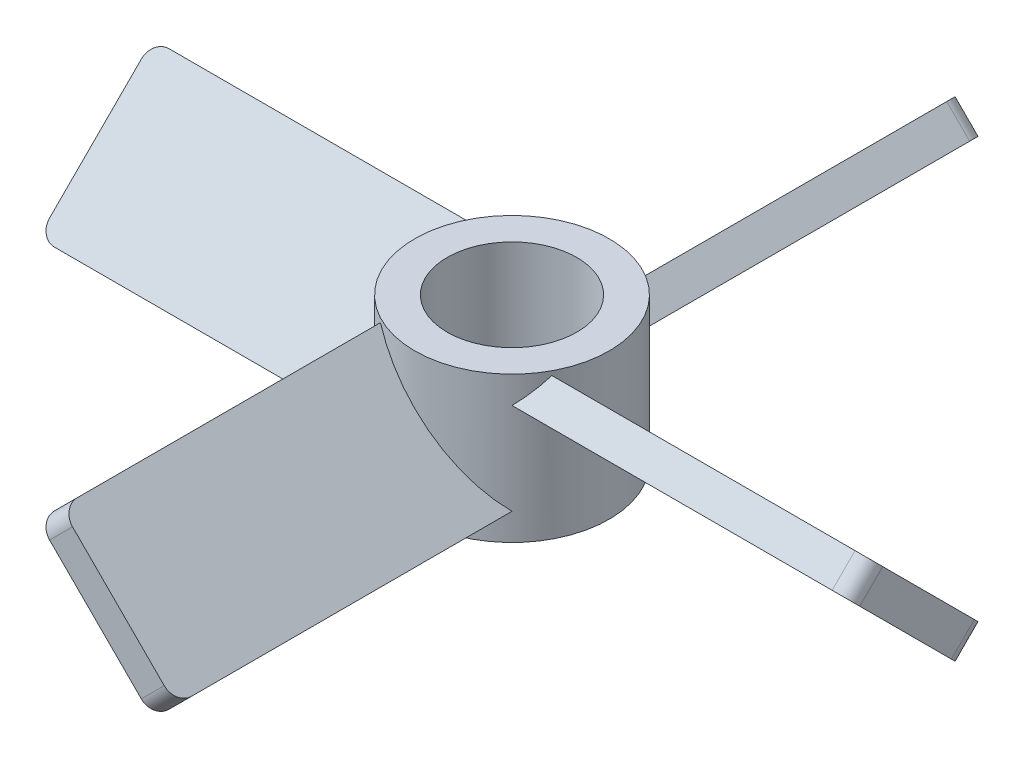
from build123d import *

# Parameters (mm, degrees)
CROQUIS3_R              = 6
SALIENTE_EXTRUIR1_DEPTH = 4.5
MATRIZC2_COUNT          = 4
CROQUIS4_R              = 4
CORTAR_EXTRUIR1_DEPTH   = 9
REDONDEO1_R             = 1


with BuildPart() as part:
    # Croquis1 → Recubrir2 section 0
    with BuildSketch(Plane(origin=(0, 0, 0), x_dir=(0, 0, -1), z_dir=(1, 0, 0))):
        Polygon((2.828427125, -4.242640687), (-4.242640687, 2.828427125), (-2.828427125, 4.242640687), (4.242640687, -2.828427125), align=None)
    # Croquis2 → Recubrir2 section 1
    with BuildSketch(Plane(origin=(21, 0, 0), x_dir=(0, 0, -1), z_dir=(1, 0, 0))):
        Polygon((4.242640687, -2.828427125), (-2.828427125, 4.242640687), (-4.242640687, 2.828427125), (2.828427125, -4.242640687), align=None)
    recubrir2 = loft()

    # Croquis3 → Saliente-Extruir1 (add, symmetric)
    with BuildSketch(Plane(origin=(0, 0, 0), x_dir=(1, 0, 0), z_dir=(0, 1, 0))):
        with Locations((-4, 0)):
            Circle(CROQUIS3_R)
    extrude(amount=SALIENTE_EXTRUIR1_DEPTH, both=True)

    # MatrizC2: Recubrir2 ×4 about axis
    matrizc2_axis = Axis((-4, 0, 0), (0, 1, 0))
    for i in range(1, MATRIZC2_COUNT):
        add(recubrir2.rotate(matrizc2_axis, i * 360 / MATRIZC2_COUNT))

    # Croquis4 → Cortar-Extruir1 (cut)
    with BuildSketch(Plane(origin=(0, 4.5, 0), x_dir=(1, 0, 0), z_dir=(0, 1, 0))):
        with Locations((-4, 0)):
            Circle(CROQUIS4_R)
    extrude(amount=-CORTAR_EXTRUIR1_DEPTH, mode=Mode.SUBTRACT)

    # Redondeo1
    redondeo1_edges = [part.edges().sort_by_distance(p)[0] for p in [
        (-7.535533906, 3.535533906, 25),
        (-0.464466094, -3.535533906, 25),
        (-29, -3.535533906, 3.535533906),
        (-29, 3.535533906, -3.535533906),
        (-7.535533906, -3.535533906, -25),
        (-0.464466094, 3.535533906, -25),
        (21, -3.535533906, -3.535533906),
        (21, 3.535533906, 3.535533906),
    ]]
    fillet(redondeo1_edges, radius=REDONDEO1_R)


solid = part.part
